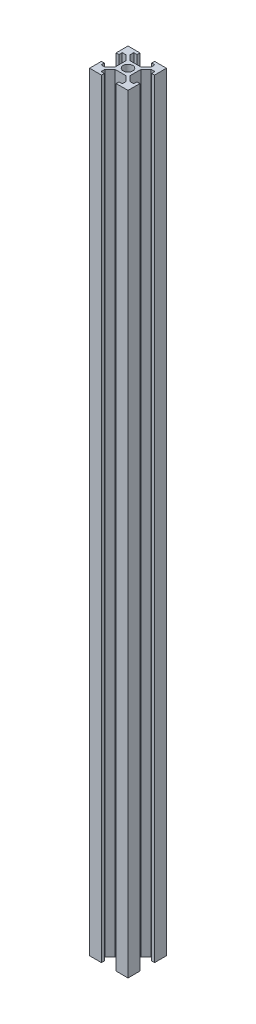
from build123d import *

# Parameters (mm, degrees)
SKETCH_1_W      = 1.5
SKETCH_1_H      = 1.7
SKETCH_1_W_2    = 1.7
SKETCH_1_H_2    = 1.5
SKETCH_1_W_3    = 7.8
SKETCH_1_H_3    = 7.8
SKETCH_1_R      = 2.5
EXTRUDE_1_DEPTH = 400


with BuildPart() as part:
    # 草图1 → 凸台-拉伸1 (new body)
    with BuildSketch(Plane(origin=(0, 0, 0), x_dir=(1, 0, 0), z_dir=(0, 1, 0))):
        Polygon((5.5, 8.5), (5.5, 6.560660172), (5.5, 5.5), (6.560660172, 5.5), (8.5, 5.5), (10, 5.5), (10, 10), (5.5, 10), align=None)
        with Locations((9.25, 4.65)):
            Rectangle(SKETCH_1_W, SKETCH_1_H)
        Polygon((5.5, 6.560660172), (2.839339828, 3.9), (3.9, 3.9), (3.9, 2.839339828), (6.560660172, 5.5), (5.5, 5.5), align=None)
        with Locations((4.65, 9.25)):
            Rectangle(SKETCH_1_W_2, SKETCH_1_H_2)
        Rectangle(SKETCH_1_W_3, SKETCH_1_H_3)
        Circle(SKETCH_1_R, mode=Mode.SUBTRACT)
        with Locations((-4.65, 9.25)):
            Rectangle(SKETCH_1_W_2, SKETCH_1_H_2)
        Polygon((-8.5, 5.5), (-6.560660172, 5.5), (-5.5, 5.5), (-5.5, 6.560660172), (-5.5, 8.5), (-5.5, 10), (-10, 10), (-10, 5.5), align=None)
        with Locations((-9.25, 4.65)):
            Rectangle(SKETCH_1_W, SKETCH_1_H)
        Polygon((-5.5, 5.5), (-6.560660172, 5.5), (-3.9, 2.839339828), (-3.9, 3.9), (-2.839339828, 3.9), (-5.5, 6.560660172), align=None)
        Polygon((-5.5, -5.5), (-6.560660172, -5.5), (-8.5, -5.5), (-10, -5.5), (-10, -10), (-5.5, -10), (-5.5, -8.5), (-5.5, -6.560660172), align=None)
        with Locations((-4.65, -9.25)):
            Rectangle(SKETCH_1_W_2, SKETCH_1_H_2)
        with Locations((-9.25, -4.65)):
            Rectangle(SKETCH_1_W, SKETCH_1_H)
        Polygon((-3.9, -3.9), (-3.9, -2.839339828), (-6.560660172, -5.5), (-5.5, -5.5), (-5.5, -6.560660172), (-2.839339828, -3.9), align=None)
        Polygon((3.9, -3.9), (2.839339828, -3.9), (5.5, -6.560660172), (5.5, -5.5), (6.560660172, -5.5), (3.9, -2.839339828), align=None)
        Polygon((5.5, -5.5), (5.5, -6.560660172), (5.5, -8.5), (5.5, -10), (10, -10), (10, -5.5), (8.5, -5.5), (6.560660172, -5.5), align=None)
        with Locations((9.25, -4.65)):
            Rectangle(SKETCH_1_W, SKETCH_1_H)
        with Locations((4.65, -9.25)):
            Rectangle(SKETCH_1_W_2, SKETCH_1_H_2)
    extrude(amount=EXTRUDE_1_DEPTH)


solid = part.part
